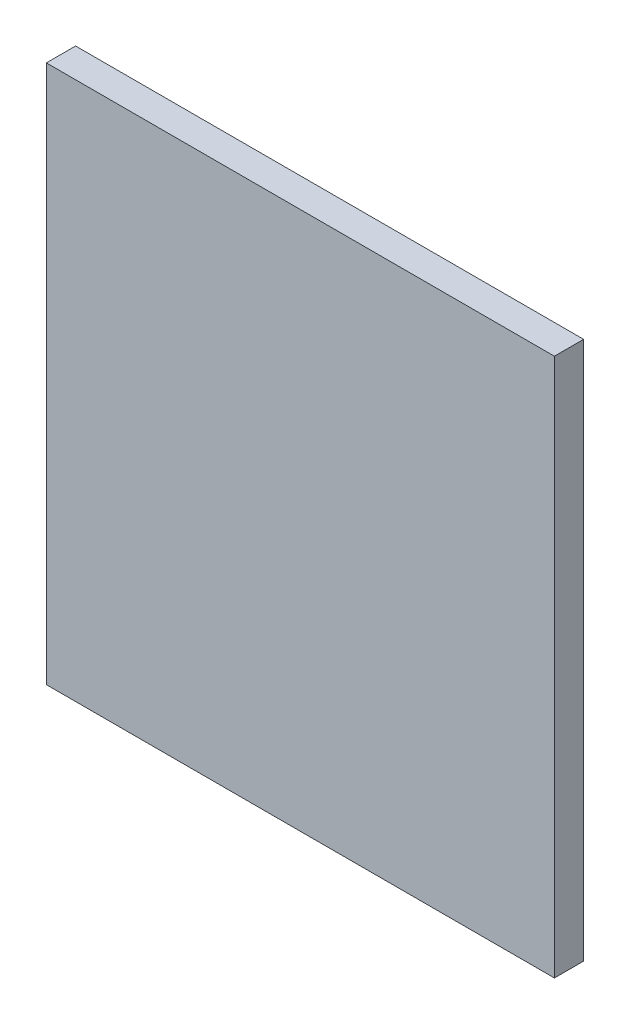
from build123d import *

# Parameters (mm, degrees)
SKETCH1_W           = 13.24
SKETCH1_H           = 14.03375
BOSS_EXTRUDE1_DEPTH = 0.762


with BuildPart() as part:
    # Sketch1 → Boss-Extrude1 (new body)
    with BuildSketch(Plane.XY):
        with Locations((-73.66, -84.3122297)):
            Rectangle(SKETCH1_W, SKETCH1_H)
    extrude(amount=BOSS_EXTRUDE1_DEPTH)


solid = part.part
